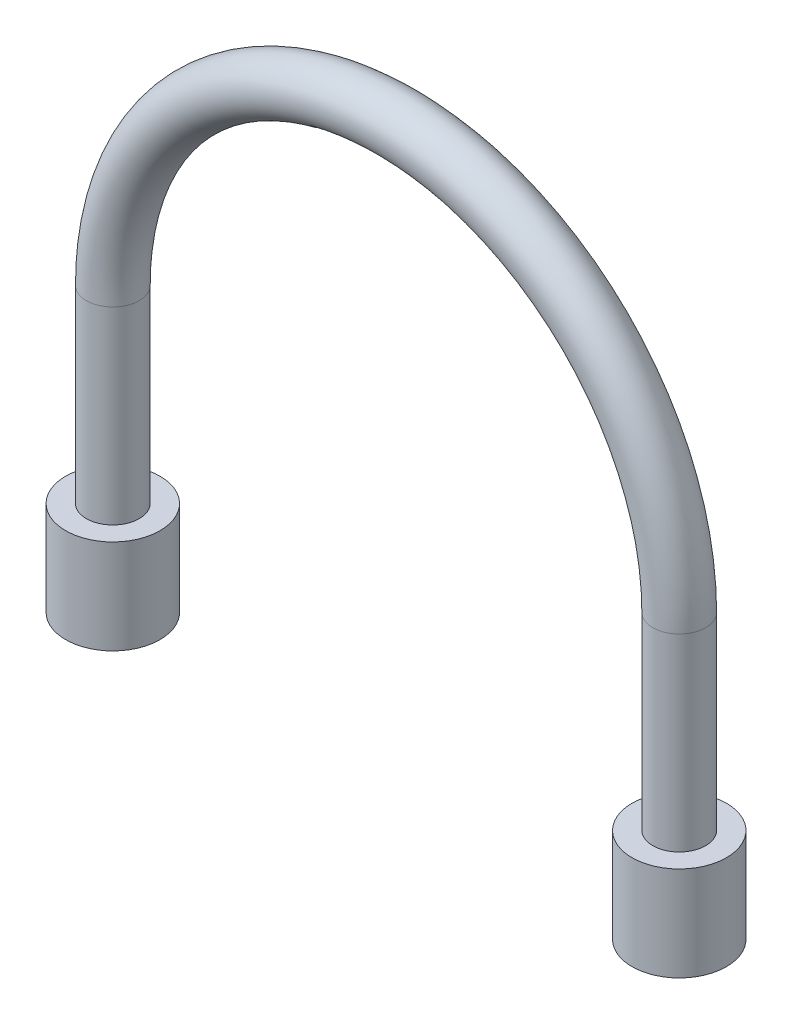
from build123d import *

# Parameters (mm, degrees)
SKETCH3_R           = 1.778
SKETCH4_R           = 3.175
BOSS_EXTRUDE1_DEPTH = 6.35
SKETCH5_R           = 3.175
BOSS_EXTRUDE2_DEPTH = 6.35
SKETCH6_W           = 8.89531995
SKETCH6_H           = 2.585925644
CUT_EXTRUDE1_DEPTH  = 2.54


with BuildPart() as part:
    # Sweep1: sweep along a path in Sketch2
    with BuildLine(Plane.XY) as sweep1_path:
        Line((-19.05, 0), (-19.05, 12.7))
        ThreePointArc((-19.05, 12.7), (0, 31.75), (19.05, 12.7))
        Line((19.05, 12.7), (19.05, 0))
    # Sketch3 → Sweep1 (sweep)
    with BuildSketch(Plane(origin=(0, 0, 0), x_dir=(1, 0, 0), z_dir=(0, 1, 0))):
        with Locations((-19.05, 0)):
            Circle(SKETCH3_R)
    sweep(path=sweep1_path.line)

    # Sketch4 → Boss-Extrude1 (add)
    with BuildSketch(Plane.XZ):
        with Locations(Location((-19.05, 0, 0), (0, 0, 270))):
            Circle(SKETCH4_R)
    extrude(amount=BOSS_EXTRUDE1_DEPTH)

    # Sketch5 → Boss-Extrude2 (add)
    with BuildSketch(Plane.XZ):
        with Locations(Location((19.05, 0, 0), (0, 0, 270))):
            Circle(SKETCH5_R)
    extrude(amount=BOSS_EXTRUDE2_DEPTH)

    # Sketch6 → Cut-Extrude1 (cut)
    with BuildSketch(Plane(origin=(0, 27.94, 0), x_dir=(1, 0, 0), z_dir=(0, 1, 0))):
        Rectangle(SKETCH6_W, SKETCH6_H)
    extrude(amount=CUT_EXTRUDE1_DEPTH, mode=Mode.SUBTRACT)


solid = part.part
